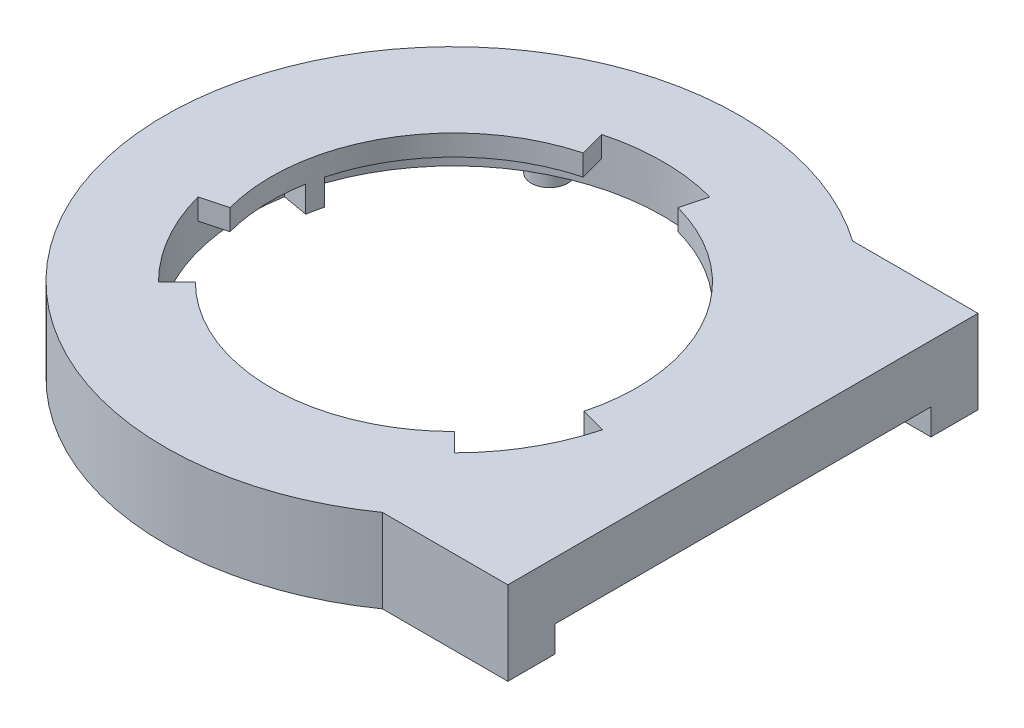
from build123d import *

# Parameters (mm, degrees)
BOSS_EXTRUDE1_DEPTH = 16
CUT_EXTRUDE1_DEPTH  = 12
SKETCH4_W           = 72
SKETCH4_H           = 5
CUT_EXTRUDE2_DEPTH  = 16
SKETCH5_R           = 35
CUT_EXTRUDE3_DEPTH  = 16
CUT_EXTRUDE4_DEPTH  = 10
SKETCH7_R           = 42
BOSS_EXTRUDE2_DEPTH = 5
SKETCH8_R           = 3.5
SKETCH8_R_2         = 1.5
BOSS_EXTRUDE3_DEPTH = 12
SKETCH9_R           = 1.5
CUT_EXTRUDE5_DEPTH  = 12


with BuildPart() as part:
    # Sketch1 → Boss-Extrude1 (new body)
    with BuildSketch(Plane(origin=(0, 0, 0), x_dir=(1, 0, 0), z_dir=(0, 1, 0))):
        with BuildLine():
            Line((24.684271836, -45.0001724), (24.684271836, 44.9998276))
            Line((24.684271836, 44.9998276), (31.307293766, 44.9998276))
            ThreePointArc((31.307293766, 44.9998276), (-55.315728163, 0.000299848), (31.306803106, -45.0001724))
            Line((31.306803106, -45.0001724), (24.684271836, -45.0001724))
        make_face()
        with BuildLine():
            Line((31.307293766, 44.9998276), (24.684271836, 44.9998276))
            Line((24.684271836, 44.9998276), (24.684271836, -45.0001724))
            Line((24.684271836, -45.0001724), (31.306803106, -45.0001724))
            ThreePointArc((31.306803106, -45.0001724), (48.491234556, -25.355086079), (54.684271836, 0))
            ThreePointArc((54.684271836, 0), (48.491372785, 25.354819994), (31.307293766, 44.9998276))
        make_face()
        with BuildLine():
            Line((55.315728164, 44.9998276), (31.307293766, 44.9998276))
            ThreePointArc((31.307293766, 44.9998276), (48.491372785, 25.354819994), (54.684271836, 0))
            ThreePointArc((54.684271836, 0), (48.491234556, -25.355086079), (31.306803106, -45.0001724))
            Line((31.306803106, -45.0001724), (55.315728164, -45.0001724))
            Line((55.315728164, -45.0001724), (55.315728164, 44.9998276))
        make_face()
    extrude(amount=BOSS_EXTRUDE1_DEPTH)

    # Sketch3 → Cut-Extrude1 (cut)
    with BuildSketch(Plane.XZ):
        with BuildLine():
            ThreePointArc((50, 0), (44.646173327, 22.510424413), (29.73123171, 40.2001724))
            Line((29.73123171, 40.2001724), (13.648760289, 40.2001724))
            Line((13.648760289, 40.2001724), (13.648760289, -40.1998276))
            Line((13.648760289, -40.1998276), (29.731697916, -40.1998276))
            ThreePointArc((29.731697916, -40.1998276), (44.646303855, -22.510165528), (50, 0))
        make_face()
        with BuildLine():
            Line((13.648760289, 40.2001724), (29.73123171, 40.2001724))
            ThreePointArc((29.73123171, 40.2001724), (-49.999999999, -0.000289929), (29.731697916, -40.1998276))
            Line((29.731697916, -40.1998276), (13.648760289, -40.1998276))
            Line((13.648760289, -40.1998276), (13.648760289, 40.2001724))
        make_face()
        with BuildLine():
            Line((50.315728164, -40.1998276), (50.315728164, 40.2001724))
            Line((50.315728164, 40.2001724), (29.73123171, 40.2001724))
            ThreePointArc((29.73123171, 40.2001724), (44.646173327, 22.510424413), (50, 0))
            ThreePointArc((50, 0), (44.646303855, -22.510165528), (29.731697916, -40.1998276))
            Line((29.731697916, -40.1998276), (50.315728164, -40.1998276))
        make_face()
    extrude(amount=-CUT_EXTRUDE1_DEPTH, mode=Mode.SUBTRACT)

    # Sketch4 → Cut-Extrude2 (cut)
    with BuildSketch(Plane(origin=(55.315728164, 0, 0), x_dir=(0, 0, -1), z_dir=(1, 0, 0))):
        with Locations((-0.0001724, 2.5)):
            Rectangle(SKETCH4_W, SKETCH4_H)
    extrude(amount=-CUT_EXTRUDE2_DEPTH, mode=Mode.SUBTRACT)

    # Sketch5 → Cut-Extrude3 (cut)
    with BuildSketch(Plane(origin=(0, 16, 0), x_dir=(1, 0, 0), z_dir=(0, 1, 0))):
        Circle(SKETCH5_R)
    extrude(amount=-CUT_EXTRUDE3_DEPTH, mode=Mode.SUBTRACT)

    # Sketch6 → Cut-Extrude4 (cut)
    with BuildSketch(Plane(origin=(0, 16, 0), x_dir=(1, 0, 0), z_dir=(0, 1, 0))):
        with BuildLine():
            Line((-28.284271247, -28.284271247), (-24.748737342, -24.748737342))
            ThreePointArc((-24.748737342, -24.748737342), (-27.76736691, -21.306650015), (-30.310889132, -17.5))
            Line((-30.310889132, -17.5), (-34.641016151, -20))
            ThreePointArc((-34.641016151, -20), (-31.734133612, -24.35045716), (-28.284271247, -28.284271247))
        make_face()
        with BuildLine():
            Line((-34.641016151, -20), (-30.310889132, -17.5))
            ThreePointArc((-30.310889132, -17.5), (-32.335783638, -13.393920133), (-33.80740392, -9.058666579))
            Line((-33.80740392, -9.058666579), (-38.637033052, -10.352761804))
            ThreePointArc((-38.637033052, -10.352761804), (-36.9551813, -15.307337295), (-34.641016151, -20))
        make_face()
        with BuildLine():
            Line((-10.352761804, 38.637033052), (-9.058666579, 33.80740392))
            ThreePointArc((-9.058666579, 33.80740392), (0, 35), (9.058666579, 33.80740392))
            Line((9.058666579, 33.80740392), (10.352761804, 38.637033052))
            ThreePointArc((10.352761804, 38.637033052), (0, 40), (-10.352761804, 38.637033052))
        make_face()
        with BuildLine():
            ThreePointArc((33.831018509, -8.970071717), (32.370760151, -13.309165535), (30.356629112, -17.420535841))
            Line((30.356629112, -17.420535841), (34.693290413, -19.909183818))
            ThreePointArc((34.693290413, -19.909183818), (36.995154458, -15.210474897), (38.664021154, -10.251510534))
            Line((38.664021154, -10.251510534), (33.831018509, -8.970071717))
        make_face()
        with BuildLine():
            ThreePointArc((30.356629112, -17.420535841), (27.823087732, -21.233835948), (24.813485607, -24.683819236))
            Line((24.813485607, -24.683819236), (28.358269265, -28.210079126))
            ThreePointArc((28.358269265, -28.210079126), (31.79781455, -24.267241084), (34.693290413, -19.909183818))
            Line((34.693290413, -19.909183818), (30.356629112, -17.420535841))
        make_face()
    extrude(amount=-CUT_EXTRUDE4_DEPTH, mode=Mode.SUBTRACT)

    # Sketch7 → Boss-Extrude2 (add)
    with BuildSketch(Plane.XZ.offset(-12)):
        Circle(SKETCH7_R)
        with BuildLine():
            ThreePointArc((-28.284271247, 28.284271247), (-10.352761804, 38.637033052), (10.352761804, 38.637033052))
            Line((10.352761804, 38.637033052), (9.058666579, 33.80740392))
            ThreePointArc((9.058666579, 33.80740392), (10.524702983, 33.380093276), (11.970705016, 32.889241728))
            Line((11.970705016, 32.889241728), (13.680805733, 37.587704831))
            ThreePointArc((13.680805733, 37.587704831), (21.53615385, 33.707478063), (28.358269265, 28.210079126))
            ThreePointArc((28.358269265, 28.210079126), (34.693290413, 19.909183818), (38.664021154, 10.251510534))
            ThreePointArc((38.664021154, 10.251510534), (38.623439557, -10.40336084), (28.284271247, -28.284271247))
            Line((28.284271247, -28.284271247), (24.748737342, -24.748737342))
            ThreePointArc((24.748737342, -24.748737342), (23.645657267, -25.804706788), (22.497566339, -26.811555509))
            Line((22.497566339, -26.811555509), (25.711504387, -30.641777725))
            ThreePointArc((25.711504387, -30.641777725), (18.469944529, -35.480433327), (10.352761804, -38.637033052))
            ThreePointArc((10.352761804, -38.637033052), (0, -40), (-10.352761804, -38.637033052))
            ThreePointArc((-10.352761804, -38.637033052), (-28.284271247, -28.284271247), (-38.637033052, -10.352761804))
            Line((-38.637033052, -10.352761804), (-33.80740392, -9.058666579))
            ThreePointArc((-33.80740392, -9.058666579), (-34.170360249, -7.575386488), (-34.468271355, -6.077686218))
            Line((-34.468271355, -6.077686218), (-39.39231012, -6.945927107))
            ThreePointArc((-39.39231012, -6.945927107), (-39.961928863, 1.744775495), (-38.637033052, 10.352761804))
            ThreePointArc((-38.637033052, 10.352761804), (-34.641016151, 20), (-28.284271247, 28.284271247))
        make_face(mode=Mode.SUBTRACT)
    extrude(amount=BOSS_EXTRUDE2_DEPTH)

    # Sketch8 → Boss-Extrude3 (add)
    with BuildSketch(Plane.XZ.offset(-12)):
        with Locations((-25, 43.301270189)):
            Circle(SKETCH8_R)
        with Locations((-25, 43.301270189)):
            Circle(SKETCH8_R_2, mode=Mode.SUBTRACT)
        with Locations((-25, -43.301270189)):
            Circle(SKETCH8_R)
        with Locations((-25, -43.301270189)):
            Circle(SKETCH8_R_2, mode=Mode.SUBTRACT)
        with Locations((31.306803106, 40.2001724)):
            Circle(SKETCH8_R)
        with Locations((31.306803106, 40.2001724)):
            Circle(SKETCH8_R_2, mode=Mode.SUBTRACT)
        with Locations((31.307293766, -40.1998276)):
            Circle(SKETCH8_R)
        with Locations((31.307293766, -40.1998276)):
            Circle(SKETCH8_R_2, mode=Mode.SUBTRACT)
    extrude(amount=BOSS_EXTRUDE3_DEPTH)

    # Sketch9 → Cut-Extrude5 (cut)
    with BuildSketch(Plane.XZ.offset(-12)):
        with Locations((-25, 43.301270189)):
            Circle(SKETCH9_R)
        with Locations((31.306803106, 40.2001724)):
            Circle(SKETCH9_R)
        with Locations((-25, -43.301270189)):
            Circle(SKETCH9_R)
        with Locations((31.307293766, -40.1998276)):
            Circle(SKETCH9_R)
    extrude(amount=CUT_EXTRUDE5_DEPTH, mode=Mode.SUBTRACT)


solid = part.part
